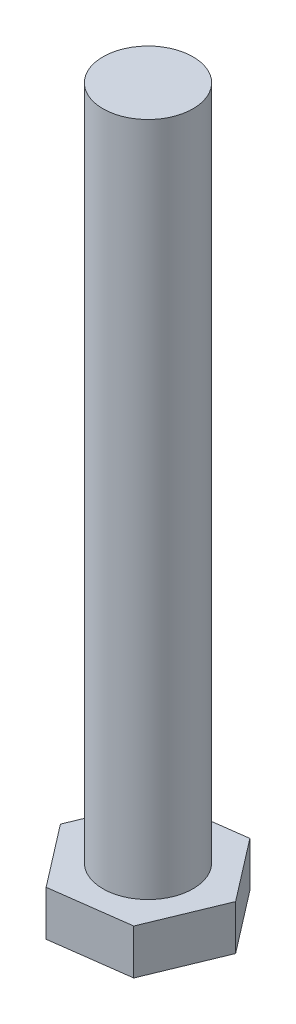
from build123d import *

# Parameters (mm, degrees)
BOSS_EXTRUDE1_DEPTH = 2
SKETCH2_R           = 2
BOSS_EXTRUDE2_DEPTH = 30


with BuildPart() as part:
    # Sketch1 → Boss-Extrude1 (new body)
    with BuildSketch(Plane(origin=(0, 0, 0), x_dir=(1, 0, 0), z_dir=(0, 1, 0))):
        Polygon((2.112100031, -2.745730041), (3.433921983, 0.456267262), (1.321821952, 3.201997303), (-2.112100031, 2.745730041), (-3.433921983, -0.456267262), (-1.321821952, -3.201997303), align=None)
    extrude(amount=BOSS_EXTRUDE1_DEPTH)

    # Sketch2 → Boss-Extrude2 (add)
    with BuildSketch(Plane(origin=(0, 2, 0), x_dir=(1, 0, 0), z_dir=(0, 1, 0))):
        Circle(SKETCH2_R)
    extrude(amount=BOSS_EXTRUDE2_DEPTH)


solid = part.part
